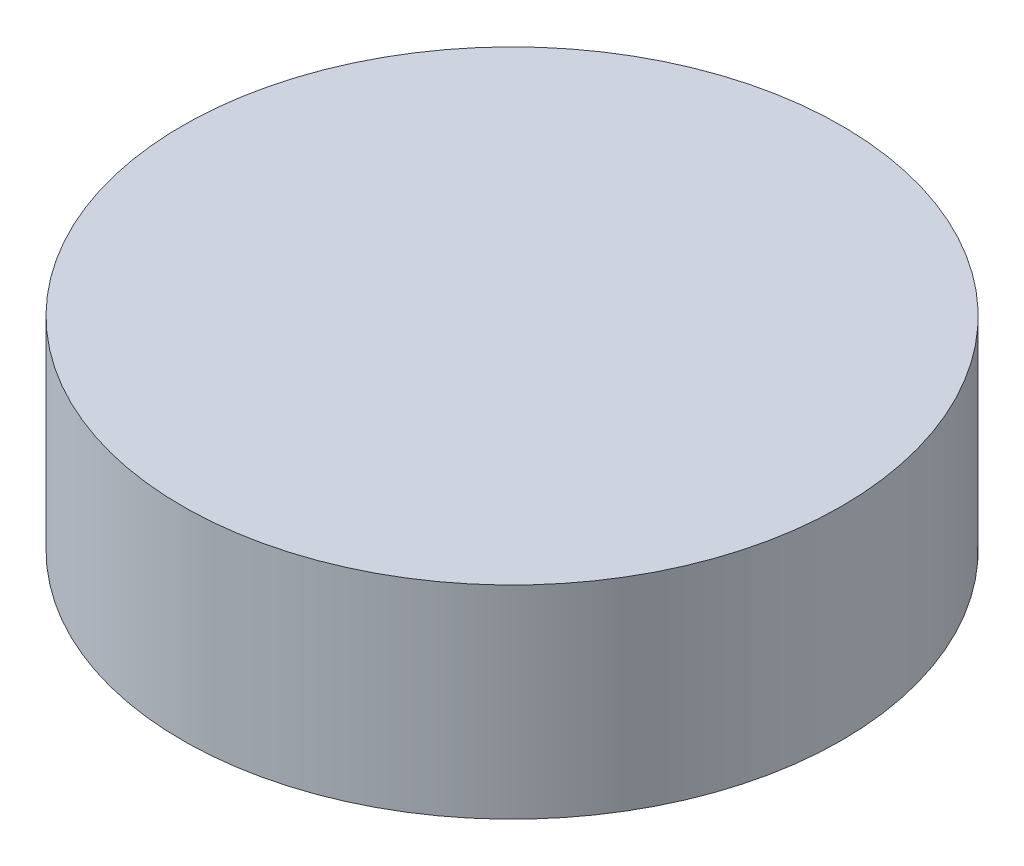
from build123d import *

# Parameters (mm, degrees)
CROQUIS1_R                   = 16.51
SALIENTE_EXTRUIR1_DEPTH      = 10.16
CORPS_D_PLACER_COPIER1_ANGLE = 90


with BuildPart() as part:
    # Croquis1 → Saliente-Extruir1 (new body)
    with BuildSketch(Plane.XY):
        Circle(CROQUIS1_R)
    extrude(amount=SALIENTE_EXTRUIR1_DEPTH)


with BuildPart() as part_1:
    # Corps-Déplacer/Copier1: moved
    add(part.part.rotate(Axis((0, 0, 0), (1, 0, 0)), CORPS_D_PLACER_COPIER1_ANGLE))


solid = part_1.part
